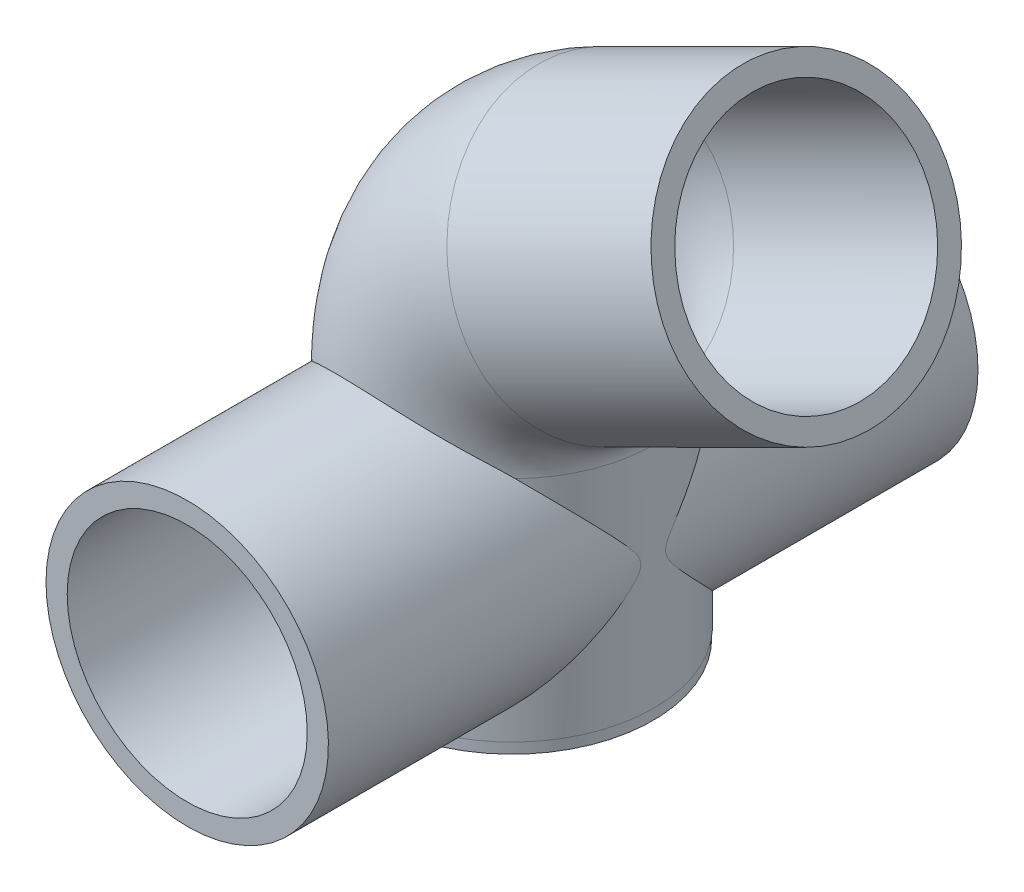
from build123d import *
from build123d.topology import SkipClean

# Parameters (mm, degrees)
CROQUIS1_R                          = 13
CROQUIS1_R_2                        = 11.05
SALIENTE_EXTRUIR1_DEPTH             = 1
BARRER_L_MINA1_PROFILE_R            = 13.05
BARRER_L_MINA1_PROFILE_R_2          = 11.05
CROQUIS35_R                         = 13
CROQUIS35_R_2                       = 11.05
SALIENTE_EXTRUIR3_DEPTH             = 15
SALIENTE_EXTRUIR3_DIRECTION_2_REACH = 73.094
CORTAR_EXTRUIR1_REACH               = 80.217
CROQUIS37_R                         = 11.05


with BuildPart() as part:
    # Croquis1 → Saliente-Extruir1 (new body)
    with BuildSketch(Plane(origin=(0, 0, 0), x_dir=(1, 0, 0), z_dir=(0, 1, 0))):
        with Locations(Location((0, 0, 0), (0, 0, 270))):
            Circle(CROQUIS1_R)
        with Locations(Location((0, 0, 0), (0, 0, 270))):
            Circle(CROQUIS1_R_2, mode=Mode.SUBTRACT)
    extrude(amount=SALIENTE_EXTRUIR1_DEPTH)

    # Barrer-L_mina1: sweep along a path in Croquis2
    with BuildLine(Plane.XY) as barrer_l_mina1_path:
        Line((0, 1), (0, 22))
        ThreePointArc((0, 22), (2.241962153, 29.88875594), (8.297662704, 35.41933958))
        Line((8.297662704, 35.41933958), (27.084738117, 44.802611794))
    # Barrer-L_mina1 profile (on start of the path) → Barrer-L_mina1 (sweep)
    with BuildSketch(Plane.ZX.offset(1)):
        Circle(BARRER_L_MINA1_PROFILE_R)
        Circle(BARRER_L_MINA1_PROFILE_R_2, mode=Mode.SUBTRACT)
    sweep(path=barrer_l_mina1_path.line)

    # Croquis35 → Saliente-Extruir3 (add)
    with BuildSketch(Plane(origin=(0, 0, -14.9), x_dir=(-1, 0, 0), z_dir=(0, 0, -1))):
        with Locations((0, 13)):
            Circle(CROQUIS35_R)
        with Locations((0, 13)):
            Circle(CROQUIS35_R_2, mode=Mode.SUBTRACT)
    saliente_extruir3 = extrude(amount=SALIENTE_EXTRUIR3_DEPTH)

    # Croquis35 → Saliente-Extruir3 direction 2 (add, up to next)
    with BuildSketch(Plane(origin=(0, 0, -14.9), x_dir=(-1, 0, 0), z_dir=(0, 0, -1)), mode=Mode.PRIVATE) as saliente_extruir3_direction_2_sk1:
        with Locations((0, 13)):
            Circle(CROQUIS35_R)
        with Locations((0, 13)):
            Circle(CROQUIS35_R_2, mode=Mode.SUBTRACT)
    saliente_extruir3_direction_2_tool1 = extrude(saliente_extruir3_direction_2_sk1.sketch, amount=-SALIENTE_EXTRUIR3_DIRECTION_2_REACH, mode=Mode.PRIVATE) - part.part
    saliente_extruir3_direction_2 = saliente_extruir3_direction_2_tool1.solids().sort_by_distance((12.632304, 13, -14.9))[0]
    add(saliente_extruir3_direction_2)

    # Croquis37 → Cortar-Extruir1 (cut, up to next)
    with BuildSketch(Plane(origin=(0, 0, -29.9), x_dir=(-1, 0, 0), z_dir=(0, 0, -1)), mode=Mode.PRIVATE) as cortar_extruir1_sk1:
        with Locations((0, 13)):
            Circle(CROQUIS37_R)
    cortar_extruir1_tool1 = extrude(cortar_extruir1_sk1.sketch, amount=-CORTAR_EXTRUIR1_REACH, mode=Mode.PRIVATE) & part.part
    cortar_extruir1 = cortar_extruir1_tool1.solids().sort_by_distance((0, 13, -29.9))[0]
    add(cortar_extruir1, mode=Mode.SUBTRACT)

    # Simetr_a1: Saliente-Extruir3, Saliente-Extruir3 direction 2, Cortar-Extruir1 across plane
    with SkipClean():  # the faces are left unmerged after this step: merging them gives an invalid solid
        add(saliente_extruir3.mirror(Plane.XY))
        add(saliente_extruir3_direction_2.mirror(Plane.XY))
        add(cortar_extruir1.mirror(Plane.XY), mode=Mode.SUBTRACT)


solid = part.part
